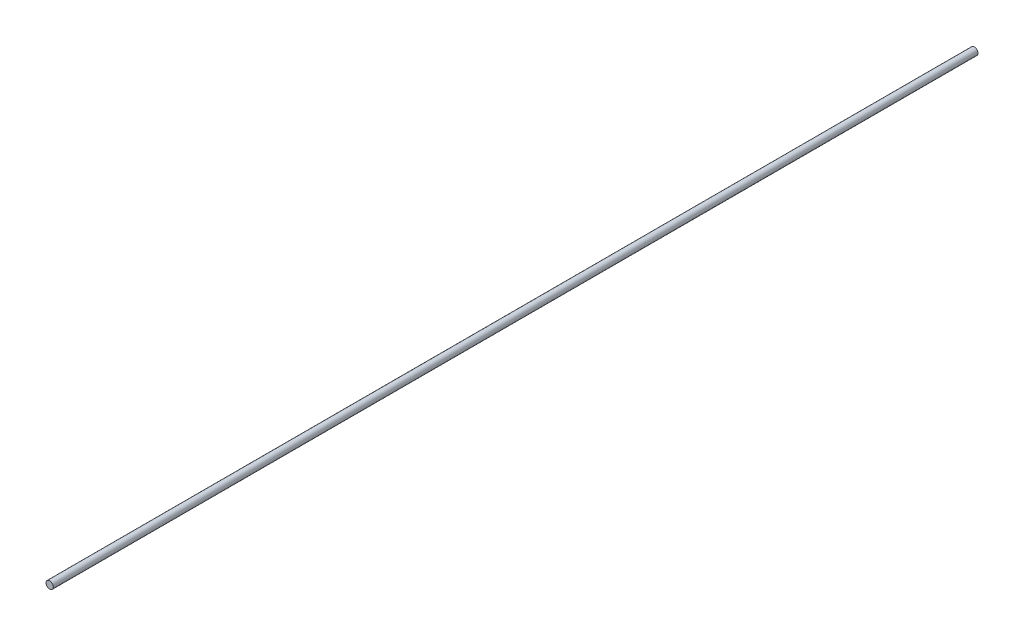
from build123d import *

# Parameters (mm, degrees)
SKETCH1_R           = 2.5
BOSS_EXTRUDE1_DEPTH = 635


with BuildPart() as part:
    # Sketch1 → Boss-Extrude1 (new body)
    with BuildSketch(Plane.XY):
        Circle(SKETCH1_R)
    extrude(amount=-BOSS_EXTRUDE1_DEPTH)


solid = part.part
